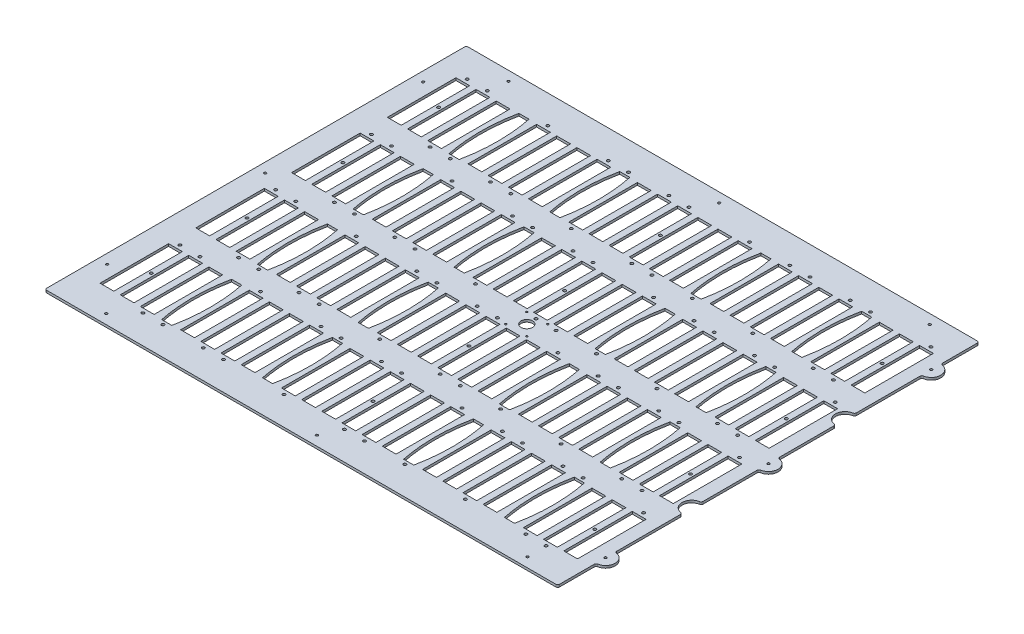
from build123d import *

# Parameters (mm, degrees)
BOSS_EXTRUDE1_DEPTH          = 3.175
SKETCH17_W                   = 18.288
SKETCH17_H                   = 90.932
CUT_EXTRUDE5_DEPTH           = 4.175
F_25_0_1495_DIAMETER_HOLE1_D = 3.7973
FILLET1_R                    = 2.54
F_6_CLEARANCE_HOLE1_D        = 3.7973
F_2_CLEARANCE_HOLE1_D        = 2.4384
SKETCH20_R                   = 7.62
CUT_EXTRUDE6_DEPTH           = 4.175
F_1_8_0_125_DIAMETER_HOLE1_D = 3.175
CUT_EXTRUDE7_DEPTH           = 4.175


with BuildPart() as part:
    # Sketch1 → Boss-Extrude1 (new body)
    with BuildSketch(Plane(origin=(0, 0, 0), x_dir=(1, 0, 0), z_dir=(0, 1, 0))):
        with BuildLine():
            Line((340.1822, 228.7524), (340.1822, 279.5524))
            Line((340.1822, 279.5524), (-340.1822, 279.5524))
            Line((-340.1822, 279.5524), (-340.1822, -279.5524))
            Line((-340.1822, -279.5524), (340.1822, -279.5524))
            Line((340.1822, -279.5524), (340.1822, -228.7524))
            ThreePointArc((340.1822, -228.7524), (352.8822, -216.0524), (340.1822, -203.3524))
            Line((340.1822, -203.3524), (340.1822, -114.4524))
            ThreePointArc((340.1822, -114.4524), (327.4822, -101.7524), (340.1822, -89.0524))
            Line((340.1822, -89.0524), (340.1822, -12.699771398))
            ThreePointArc((340.1822, -12.699771398), (352.9584, 0), (340.1822, 12.699771398))
            Line((340.1822, 12.699771398), (340.1822, 89.0524))
            ThreePointArc((340.1822, 89.0524), (327.4822, 101.7524), (340.1822, 114.4524))
            Line((340.1822, 114.4524), (340.1822, 203.3524))
            ThreePointArc((340.1822, 203.3524), (352.8822, 216.0524), (340.1822, 228.7524))
        make_face()
    extrude(amount=BOSS_EXTRUDE1_DEPTH)

    # Sketch17 → Cut-Extrude5 (cut, through all)
    with BuildSketch(Plane(origin=(0, 3.175, 0), x_dir=(1, 0, 0), z_dir=(0, 1, 0))):
        with Locations((-274.623695652, 190.6524)):
            Rectangle(SKETCH17_W, SKETCH17_H)
        with Locations((-301.371, 190.6524)):
            Rectangle(SKETCH17_W, SKETCH17_H)
        with Locations((-247.876391304, 190.6524)):
            Rectangle(SKETCH17_W, SKETCH17_H)
        with Locations((-194.381782609, 190.6524)):
            Rectangle(SKETCH17_W, SKETCH17_H)
        with Locations((-167.634478261, 190.6524)):
            Rectangle(SKETCH17_W, SKETCH17_H)
        with Locations((-140.887173913, 190.6524)):
            Rectangle(SKETCH17_W, SKETCH17_H)
        with Locations((-114.139869565, 190.6524)):
            Rectangle(SKETCH17_W, SKETCH17_H)
        with Locations((-60.64526087, 190.6524)):
            Rectangle(SKETCH17_W, SKETCH17_H)
        with Locations((-33.897956522, 190.6524)):
            Rectangle(SKETCH17_W, SKETCH17_H)
        with Locations((-7.150652174, 190.6524)):
            Rectangle(SKETCH17_W, SKETCH17_H)
        with Locations((19.596652174, 190.6524)):
            Rectangle(SKETCH17_W, SKETCH17_H)
        with Locations((46.343956522, 190.6524)):
            Rectangle(SKETCH17_W, SKETCH17_H)
        with Locations((73.09126087, 190.6524)):
            Rectangle(SKETCH17_W, SKETCH17_H)
        with Locations((126.585869565, 190.6524)):
            Rectangle(SKETCH17_W, SKETCH17_H)
        with Locations((153.333173913, 190.6524)):
            Rectangle(SKETCH17_W, SKETCH17_H)
        with Locations((180.080478261, 190.6524)):
            Rectangle(SKETCH17_W, SKETCH17_H)
        with Locations((206.827782609, 190.6524)):
            Rectangle(SKETCH17_W, SKETCH17_H)
        with Locations((260.322391304, 190.6524)):
            Rectangle(SKETCH17_W, SKETCH17_H)
        with Locations((287.069695652, 190.6524)):
            Rectangle(SKETCH17_W, SKETCH17_H)
        with Locations((313.817, 190.6524)):
            Rectangle(SKETCH17_W, SKETCH17_H)
        with Locations((-274.623695652, 63.5762)):
            Rectangle(SKETCH17_W, SKETCH17_H)
        with Locations((-247.876391304, 63.5762)):
            Rectangle(SKETCH17_W, SKETCH17_H)
        with Locations((-194.381782609, 63.5762)):
            Rectangle(SKETCH17_W, SKETCH17_H)
        with Locations((-167.634478261, 63.5762)):
            Rectangle(SKETCH17_W, SKETCH17_H)
        with Locations((-140.887173913, 63.5762)):
            Rectangle(SKETCH17_W, SKETCH17_H)
        with Locations((-114.139869565, 63.5762)):
            Rectangle(SKETCH17_W, SKETCH17_H)
        with Locations((-60.64526087, 63.5762)):
            Rectangle(SKETCH17_W, SKETCH17_H)
        with Locations((-33.897956522, 63.5762)):
            Rectangle(SKETCH17_W, SKETCH17_H)
        with Locations((-7.150652174, 63.5762)):
            Rectangle(SKETCH17_W, SKETCH17_H)
        with Locations((19.596652174, 63.5762)):
            Rectangle(SKETCH17_W, SKETCH17_H)
        with Locations((46.343956522, 63.5762)):
            Rectangle(SKETCH17_W, SKETCH17_H)
        with Locations((73.09126087, 63.5762)):
            Rectangle(SKETCH17_W, SKETCH17_H)
        with Locations((126.585869565, 63.5762)):
            Rectangle(SKETCH17_W, SKETCH17_H)
        with Locations((153.333173913, 63.5762)):
            Rectangle(SKETCH17_W, SKETCH17_H)
        with Locations((180.080478261, 63.5762)):
            Rectangle(SKETCH17_W, SKETCH17_H)
        with Locations((206.827782609, 63.5762)):
            Rectangle(SKETCH17_W, SKETCH17_H)
        with Locations((260.322391304, 63.5762)):
            Rectangle(SKETCH17_W, SKETCH17_H)
        with Locations((287.069695652, 63.5762)):
            Rectangle(SKETCH17_W, SKETCH17_H)
        with Locations((313.817, 63.5762)):
            Rectangle(SKETCH17_W, SKETCH17_H)
        with Locations((-274.623695652, -63.5)):
            Rectangle(SKETCH17_W, SKETCH17_H)
        with Locations((-247.876391304, -63.5)):
            Rectangle(SKETCH17_W, SKETCH17_H)
        with Locations((-194.381782609, -63.5)):
            Rectangle(SKETCH17_W, SKETCH17_H)
        with Locations((-167.634478261, -63.5)):
            Rectangle(SKETCH17_W, SKETCH17_H)
        with Locations((-140.887173913, -63.5)):
            Rectangle(SKETCH17_W, SKETCH17_H)
        with Locations((-114.139869565, -63.5)):
            Rectangle(SKETCH17_W, SKETCH17_H)
        with Locations((-60.64526087, -63.5)):
            Rectangle(SKETCH17_W, SKETCH17_H)
        with Locations((-33.897956522, -63.5)):
            Rectangle(SKETCH17_W, SKETCH17_H)
        with Locations((-7.150652174, -63.5)):
            Rectangle(SKETCH17_W, SKETCH17_H)
        with Locations((19.596652174, -63.5)):
            Rectangle(SKETCH17_W, SKETCH17_H)
        with Locations((46.343956522, -63.5)):
            Rectangle(SKETCH17_W, SKETCH17_H)
        with Locations((73.09126087, -63.5)):
            Rectangle(SKETCH17_W, SKETCH17_H)
        with Locations((126.585869565, -63.5)):
            Rectangle(SKETCH17_W, SKETCH17_H)
        with Locations((153.333173913, -63.5)):
            Rectangle(SKETCH17_W, SKETCH17_H)
        with Locations((180.080478261, -63.5)):
            Rectangle(SKETCH17_W, SKETCH17_H)
        with Locations((206.827782609, -63.5)):
            Rectangle(SKETCH17_W, SKETCH17_H)
        with Locations((260.322391304, -63.5)):
            Rectangle(SKETCH17_W, SKETCH17_H)
        with Locations((287.069695652, -63.5)):
            Rectangle(SKETCH17_W, SKETCH17_H)
        with Locations((313.817, -63.5)):
            Rectangle(SKETCH17_W, SKETCH17_H)
        with Locations((-274.623695652, -190.5762)):
            Rectangle(SKETCH17_W, SKETCH17_H)
        with Locations((-247.876391304, -190.5762)):
            Rectangle(SKETCH17_W, SKETCH17_H)
        with Locations((-194.381782609, -190.5762)):
            Rectangle(SKETCH17_W, SKETCH17_H)
        with Locations((-167.634478261, -190.5762)):
            Rectangle(SKETCH17_W, SKETCH17_H)
        with Locations((-140.887173913, -190.5762)):
            Rectangle(SKETCH17_W, SKETCH17_H)
        with Locations((-114.139869565, -190.5762)):
            Rectangle(SKETCH17_W, SKETCH17_H)
        with Locations((-60.64526087, -190.5762)):
            Rectangle(SKETCH17_W, SKETCH17_H)
        with Locations((-33.897956522, -190.5762)):
            Rectangle(SKETCH17_W, SKETCH17_H)
        with Locations((-7.150652174, -190.5762)):
            Rectangle(SKETCH17_W, SKETCH17_H)
        with Locations((19.596652174, -190.5762)):
            Rectangle(SKETCH17_W, SKETCH17_H)
        with Locations((46.343956522, -190.5762)):
            Rectangle(SKETCH17_W, SKETCH17_H)
        with Locations((73.09126087, -190.5762)):
            Rectangle(SKETCH17_W, SKETCH17_H)
        with Locations((126.585869565, -190.5762)):
            Rectangle(SKETCH17_W, SKETCH17_H)
        with Locations((153.333173913, -190.5762)):
            Rectangle(SKETCH17_W, SKETCH17_H)
        with Locations((180.080478261, -190.5762)):
            Rectangle(SKETCH17_W, SKETCH17_H)
        with Locations((206.827782609, -190.5762)):
            Rectangle(SKETCH17_W, SKETCH17_H)
        with Locations((260.322391304, -190.5762)):
            Rectangle(SKETCH17_W, SKETCH17_H)
        with Locations((287.069695652, -190.5762)):
            Rectangle(SKETCH17_W, SKETCH17_H)
        with Locations((313.817, -190.5762)):
            Rectangle(SKETCH17_W, SKETCH17_H)
        with Locations((-301.371, 63.5762)):
            Rectangle(SKETCH17_W, SKETCH17_H)
        with Locations((-301.371, -63.5)):
            Rectangle(SKETCH17_W, SKETCH17_H)
        with Locations((-301.371, -190.5762)):
            Rectangle(SKETCH17_W, SKETCH17_H)
    extrude(amount=-CUT_EXTRUDE5_DEPTH, mode=Mode.SUBTRACT)

    # #25 (0.1495) Diameter Hole1 (through all)
    with Locations(Plane(origin=(0, 3.175, 0), x_dir=(1, 0, 0), z_dir=(0, 1, 0))):
        with Locations((313.817, -139.2682), (-301.447239116, 241.9604), (-274.696620024, 241.9604), (-247.946000932, 139.3444), (-221.19538184, 139.3444), (-194.444762748, 241.9604), (-167.694143656, 139.3444), (-140.943524564, 139.3444), (-114.192905472, 241.9604), (-87.44228638, 241.9604), (-60.691667288, 139.3444), (-33.941048196, 241.9604), (-7.190429104, 241.9604), (19.560189988, 139.3444), (46.31080908, 139.3444), (73.061428172, 241.9604), (99.812047264, 139.3444), (126.562666356, 241.9604), (153.313285448, 241.9604), (180.06390454, 139.3444), (206.814523632, 241.9604), (233.565142724, 241.9604), (260.315761816, 139.3444), (287.066380908, 139.3444), (313.817, 241.9604), (-301.447239116, 114.8842), (-274.696620024, 114.8842), (-247.946000932, 12.2682), (-221.19538184, 12.2682), (-194.444762748, 114.8842), (-167.694143656, 12.2682), (-140.943524564, 12.2682), (-114.192905472, 114.8842), (-87.44228638, 114.8842), (-60.691667288, 12.2682), (-33.941048196, 114.8842), (-7.190429104, 114.8842), (19.560189988, 12.2682), (46.31080908, 12.2682), (73.061428172, 114.8842), (99.812047264, 12.2682), (126.562666356, 114.8842), (153.313285448, 114.8842), (180.06390454, 12.2682), (206.814523632, 114.8842), (233.565142724, 114.8842), (260.315761816, 12.2682), (287.066380908, 12.2682), (313.817, 114.8842), (-301.447239116, -12.192), (-274.696620024, -12.192), (-247.946000932, -114.808), (-221.19538184, -114.808), (-194.444762748, -12.192), (-167.694143656, -114.808), (-140.943524564, -114.808), (-114.192905472, -12.192), (-87.44228638, -12.192), (-60.691667288, -114.808), (-33.941048196, -12.192), (-7.190429104, -12.192), (19.560189988, -114.808), (46.31080908, -114.808), (73.061428172, -12.192), (99.812047264, -114.808), (126.562666356, -12.192), (153.313285448, -12.192), (180.06390454, -114.808), (206.814523632, -12.192), (233.565142724, -12.192), (260.315761816, -114.808), (287.066380908, -114.808), (313.817, -12.192), (-301.447239116, -139.2682), (-274.696620024, -139.2682), (-247.946000932, -241.8842), (-221.19538184, -241.8842), (-194.444762748, -139.2682), (-167.694143656, -241.8842), (-140.943524564, -241.8842), (-114.192905472, -139.2682), (-87.44228638, -139.2682), (-60.691667288, -241.8842), (-33.941048196, -139.2682), (-7.190429104, -139.2682), (19.560189988, -241.8842), (46.31080908, -241.8842), (73.061428172, -139.2682), (99.812047264, -241.8842), (126.562666356, -139.2682), (153.313285448, -139.2682), (180.06390454, -241.8842), (206.814523632, -139.2682), (233.565142724, -139.2682), (260.315761816, -241.8842), (287.066380908, -241.8842)):
            Hole(F_25_0_1495_DIAMETER_HOLE1_D / 2)

    # Fillet1
    fillet1_edges = [part.edges().sort_by_distance(p)[0] for p in [
        (340.1822, 1.5875, -279.5524),
        (340.1822, 1.5875, -228.7524),
        (340.1822, 1.5875, -203.3524),
        (340.1822, 1.5875, -114.4524),
        (340.1822, 1.5875, -89.0524),
        (340.1822, 1.5875, -12.699771398),
        (340.1822, 1.5875, 12.699771398),
        (340.1822, 1.5875, 89.0524),
        (340.1822, 1.5875, 114.4524),
        (340.1822, 1.5875, 203.3524),
        (340.1822, 1.5875, 228.7524),
        (340.1822, 1.5875, 279.5524),
        (-340.1822, 1.5875, 279.5524),
        (-340.1822, 1.5875, -279.5524),
    ]]
    fillet(fillet1_edges, radius=FILLET1_R)

    # #6 Clearance Hole1 (through all)
    with Locations(Plane(origin=(0, 3.175, 0), x_dir=(1, 0, 0), z_dir=(0, 1, 0))):
        with Locations((300.443347826, -190.5762), (-287.997347826, 190.6524), (6.223, 190.6524), (300.443347826, 190.6524), (-287.997347826, 63.5762), (6.223, 63.5762), (300.443347826, 63.5762), (-287.997347826, -63.5), (6.223, -63.5), (300.443347826, -63.5), (-287.997347826, -190.5762), (6.223, -190.5762)):
            Hole(F_6_CLEARANCE_HOLE1_D / 2)

    # #2 Clearance Hole1 (through all)
    with Locations(Plane(origin=(0, 3.175, 0), x_dir=(1, 0, 0), z_dir=(0, 1, 0))):
        with Locations((33.5661, 14.0081), (5.6261, 14.0081), (5.6261, -13.9319), (33.5661, -13.9319)):
            Hole(F_2_CLEARANCE_HOLE1_D / 2)

    # Sketch20 → Cut-Extrude6 (cut, through all)
    with BuildSketch(Plane(origin=(0, 3.175, 0), x_dir=(1, 0, 0), z_dir=(0, 1, 0))):
        with Locations((19.5961, 0.0381)):
            Circle(SKETCH20_R)
    extrude(amount=-CUT_EXTRUDE6_DEPTH, mode=Mode.SUBTRACT)

    # 1/8 (0.125) Diameter Hole1 (through all)
    with Locations(Plane(origin=(0, 3.175, 0), x_dir=(1, 0, 0), z_dir=(0, 1, 0))):
        with Locations((287.3502, 266.8524), (287.3502, -266.8524), (7.9502, -266.8524), (-271.4498, -266.8524), (-327.4822, -209.55), (-327.4822, 0), (-327.4822, 209.55), (-271.4498, 266.8524), (7.9502, 266.8524), (340.1822, 216.0524), (340.2584, 0), (340.1822, -216.0524)):
            Hole(F_1_8_0_125_DIAMETER_HOLE1_D / 2)

    # Sketch23 → Cut-Extrude7 (cut, through all)
    with BuildSketch(Plane(origin=(0, 3.175, 0), x_dir=(1, 0, 0), z_dir=(0, 1, 0))):
        with BuildLine():
            Line((-94.123564997, 237.0074), (-80.661564997, 237.0074))
            add(Edge.make_bspline(
                [(-80.661564997, 237.0074), (-71.263564997, 190.6524), (-80.661564997, 144.2974)],
                knots=[0, 0, 0, 1, 1, 1], degree=2))
            Line((-80.661564997, 144.2974), (-94.123564997, 144.2974))
            add(Edge.make_bspline(
                [(-94.123564997, 237.0074), (-103.521564997, 190.6524), (-94.123564997, 144.2974)],
                knots=[0, 0, 0, 1, 1, 1], degree=2))
        make_face()
        with BuildLine():
            Line((-227.860086957, 237.0074), (-214.398086957, 237.0074))
            add(Edge.make_bspline(
                [(-214.398086957, 237.0074), (-205.000086957, 190.6524), (-214.398086957, 144.2974)],
                knots=[0, 0, 0, 1, 1, 1], degree=2))
            Line((-214.398086957, 144.2974), (-227.860086957, 144.2974))
            add(Edge.make_bspline(
                [(-227.860086957, 237.0074), (-237.258086957, 190.6524), (-227.860086957, 144.2974)],
                knots=[0, 0, 0, 1, 1, 1], degree=2))
        make_face()
        with BuildLine():
            Line((226.844087707, 144.2974), (240.306087707, 144.2974))
            add(Edge.make_bspline(
                [(240.306087707, 237.0074), (249.704087707, 190.6524), (240.306087707, 144.2974)],
                knots=[0, 0, 0, 1, 1, 1], degree=2))
            Line((240.306087707, 237.0074), (226.844087707, 237.0074))
            add(Edge.make_bspline(
                [(226.844087707, 237.0074), (217.446087707, 190.6524), (226.844087707, 144.2974)],
                knots=[0, 0, 0, 1, 1, 1], degree=2))
        make_face()
        with BuildLine():
            Line((93.107565747, 237.0074), (106.569565747, 237.0074))
            add(Edge.make_bspline(
                [(106.569565747, 237.0074), (115.967565747, 190.6524), (106.569565747, 144.2974)],
                knots=[0, 0, 0, 1, 1, 1], degree=2))
            Line((106.569565747, 144.2974), (93.107565747, 144.2974))
            add(Edge.make_bspline(
                [(93.107565747, 237.0074), (83.709565747, 190.6524), (93.107565747, 144.2974)],
                knots=[0, 0, 0, 1, 1, 1], degree=2))
        make_face()
        with BuildLine():
            Line((-227.860086957, 109.9312), (-214.398086957, 109.9312))
            add(Edge.make_bspline(
                [(-214.398086957, 109.9312), (-205.000086957, 63.5762), (-214.398086957, 17.2212)],
                knots=[0, 0, 0, 1, 1, 1], degree=2))
            Line((-214.398086957, 17.2212), (-227.860086957, 17.2212))
            add(Edge.make_bspline(
                [(-227.860086957, 109.9312), (-237.258086957, 63.5762), (-227.860086957, 17.2212)],
                knots=[0, 0, 0, 1, 1, 1], degree=2))
        make_face()
        with BuildLine():
            Line((-94.123564997, 109.9312), (-80.661564997, 109.9312))
            add(Edge.make_bspline(
                [(-80.661564997, 109.9312), (-71.263564997, 63.5762), (-80.661564997, 17.2212)],
                knots=[0, 0, 0, 1, 1, 1], degree=2))
            Line((-80.661564997, 17.2212), (-94.123564997, 17.2212))
            add(Edge.make_bspline(
                [(-94.123564997, 109.9312), (-103.521564997, 63.5762), (-94.123564997, 17.2212)],
                knots=[0, 0, 0, 1, 1, 1], degree=2))
        make_face()
        with BuildLine():
            Line((226.844087707, 17.2212), (240.306087707, 17.2212))
            add(Edge.make_bspline(
                [(240.306087707, 109.9312), (249.704087707, 63.5762), (240.306087707, 17.2212)],
                knots=[0, 0, 0, 1, 1, 1], degree=2))
            Line((240.306087707, 109.9312), (226.844087707, 109.9312))
            add(Edge.make_bspline(
                [(226.844087707, 109.9312), (217.446087707, 63.5762), (226.844087707, 17.2212)],
                knots=[0, 0, 0, 1, 1, 1], degree=2))
        make_face()
        with BuildLine():
            Line((93.107565747, 109.9312), (106.569565747, 109.9312))
            add(Edge.make_bspline(
                [(106.569565747, 109.9312), (115.967565747, 63.5762), (106.569565747, 17.2212)],
                knots=[0, 0, 0, 1, 1, 1], degree=2))
            Line((106.569565747, 17.2212), (93.107565747, 17.2212))
            add(Edge.make_bspline(
                [(93.107565747, 109.9312), (83.709565747, 63.5762), (93.107565747, 17.2212)],
                knots=[0, 0, 0, 1, 1, 1], degree=2))
        make_face()
        with BuildLine():
            Line((-227.860086957, -17.145), (-214.398086957, -17.145))
            add(Edge.make_bspline(
                [(-214.398086957, -17.145), (-205.000086957, -63.5), (-214.398086957, -109.855)],
                knots=[0, 0, 0, 1, 1, 1], degree=2))
            Line((-214.398086957, -109.855), (-227.860086957, -109.855))
            add(Edge.make_bspline(
                [(-227.860086957, -17.145), (-237.258086957, -63.5), (-227.860086957, -109.855)],
                knots=[0, 0, 0, 1, 1, 1], degree=2))
        make_face()
        with BuildLine():
            Line((-94.123564997, -17.145), (-80.661564997, -17.145))
            add(Edge.make_bspline(
                [(-80.661564997, -17.145), (-71.263564997, -63.5), (-80.661564997, -109.855)],
                knots=[0, 0, 0, 1, 1, 1], degree=2))
            Line((-80.661564997, -109.855), (-94.123564997, -109.855))
            add(Edge.make_bspline(
                [(-94.123564997, -17.145), (-103.521564997, -63.5), (-94.123564997, -109.855)],
                knots=[0, 0, 0, 1, 1, 1], degree=2))
        make_face()
        with BuildLine():
            Line((226.844087707, -109.855), (240.306087707, -109.855))
            add(Edge.make_bspline(
                [(240.306087707, -17.145), (249.704087707, -63.5), (240.306087707, -109.855)],
                knots=[0, 0, 0, 1, 1, 1], degree=2))
            Line((240.306087707, -17.145), (226.844087707, -17.145))
            add(Edge.make_bspline(
                [(226.844087707, -17.145), (217.446087707, -63.5), (226.844087707, -109.855)],
                knots=[0, 0, 0, 1, 1, 1], degree=2))
        make_face()
        with BuildLine():
            Line((93.107565747, -17.145), (106.569565747, -17.145))
            add(Edge.make_bspline(
                [(106.569565747, -17.145), (115.967565747, -63.5), (106.569565747, -109.855)],
                knots=[0, 0, 0, 1, 1, 1], degree=2))
            Line((106.569565747, -109.855), (93.107565747, -109.855))
            add(Edge.make_bspline(
                [(93.107565747, -17.145), (83.709565747, -63.5), (93.107565747, -109.855)],
                knots=[0, 0, 0, 1, 1, 1], degree=2))
        make_face()
        with BuildLine():
            Line((-227.860086957, -144.2212), (-214.398086957, -144.2212))
            add(Edge.make_bspline(
                [(-214.398086957, -144.2212), (-205.000086957, -190.5762), (-214.398086957, -236.9312)],
                knots=[0, 0, 0, 1, 1, 1], degree=2))
            Line((-214.398086957, -236.9312), (-227.860086957, -236.9312))
            add(Edge.make_bspline(
                [(-227.860086957, -144.2212), (-237.258086957, -190.5762), (-227.860086957, -236.9312)],
                knots=[0, 0, 0, 1, 1, 1], degree=2))
        make_face()
        with BuildLine():
            Line((-94.123564997, -144.2212), (-80.661564997, -144.2212))
            add(Edge.make_bspline(
                [(-80.661564997, -144.2212), (-71.263564997, -190.5762), (-80.661564997, -236.9312)],
                knots=[0, 0, 0, 1, 1, 1], degree=2))
            Line((-80.661564997, -236.9312), (-94.123564997, -236.9312))
            add(Edge.make_bspline(
                [(-94.123564997, -144.2212), (-103.521564997, -190.5762), (-94.123564997, -236.9312)],
                knots=[0, 0, 0, 1, 1, 1], degree=2))
        make_face()
        with BuildLine():
            Line((226.844087707, -236.9312), (240.306087707, -236.9312))
            add(Edge.make_bspline(
                [(240.306087707, -144.2212), (249.704087707, -190.5762), (240.306087707, -236.9312)],
                knots=[0, 0, 0, 1, 1, 1], degree=2))
            Line((240.306087707, -144.2212), (226.844087707, -144.2212))
            add(Edge.make_bspline(
                [(226.844087707, -144.2212), (217.446087707, -190.5762), (226.844087707, -236.9312)],
                knots=[0, 0, 0, 1, 1, 1], degree=2))
        make_face()
        with BuildLine():
            Line((93.107565747, -144.2212), (106.569565747, -144.2212))
            add(Edge.make_bspline(
                [(106.569565747, -144.2212), (115.967565747, -190.5762), (106.569565747, -236.9312)],
                knots=[0, 0, 0, 1, 1, 1], degree=2))
            Line((106.569565747, -236.9312), (93.107565747, -236.9312))
            add(Edge.make_bspline(
                [(93.107565747, -144.2212), (83.709565747, -190.5762), (93.107565747, -236.9312)],
                knots=[0, 0, 0, 1, 1, 1], degree=2))
        make_face()
    extrude(amount=-CUT_EXTRUDE7_DEPTH, mode=Mode.SUBTRACT)


solid = part.part
